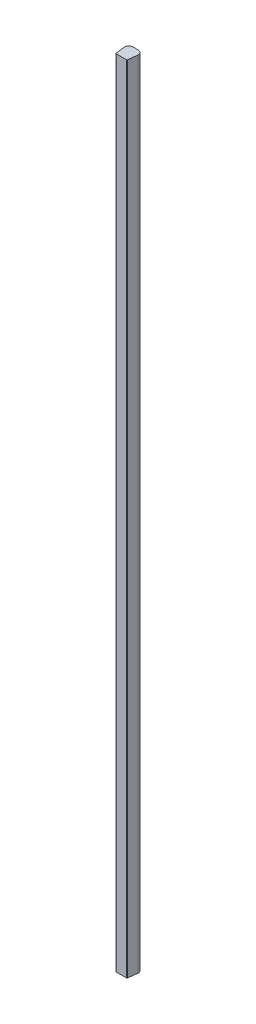
from build123d import *

# Parameters (mm, degrees)
BOSS_EXTRUDE1_DEPTH = 2133.6


with BuildPart() as part:
    # Sketch1 → Boss-Extrude1 (new body)
    with BuildSketch(Plane(origin=(0, 0, 0), x_dir=(1, 0, 0), z_dir=(0, 1, 0))):
        with BuildLine():
            Line((13.630161568, 10), (23.630161568, 10))
            ThreePointArc((23.630161568, 10), (29.962715696, 8.909575546), (34.999417241, 4.919349386))
            ThreePointArc((34.999417241, 4.919349386), (36.697471107, 1.472711464), (36.970576624, -2.359795976))
            Line((36.970576624, -2.359795976), (33.961097926, -26.870033055))
            ThreePointArc((33.961097926, -26.870033055), (33.301245719, -28.12420581), (31.976005623, -28.626294369))
            Line((31.976005623, -28.626294369), (5.284317513, -28.626294369))
            ThreePointArc((5.284317513, -28.626294369), (3.959077417, -28.12420581), (3.29922521, -26.870033055))
            Line((3.29922521, -26.870033055), (0.298191514, -2.428574989))
            ThreePointArc((0.298191514, -2.428574989), (0.53721959, 1.274672171), (2.110183266, 4.635767116))
            ThreePointArc((2.110183266, 4.635767116), (7.170061398, 8.821409583), (13.630161568, 10))
        make_face()
    extrude(amount=BOSS_EXTRUDE1_DEPTH)


solid = part.part
